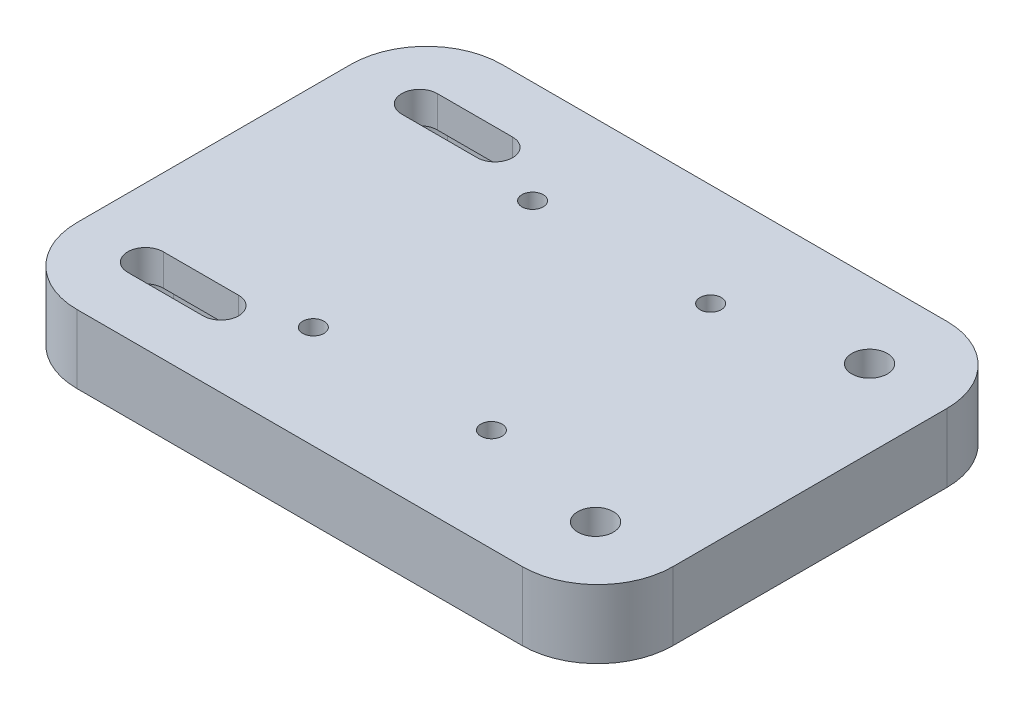
from build123d import *

# Parameters (mm, degrees)
BOSS_EXTRUDE1_DEPTH = 10
CUT_EXTRUDE5_REACH  = 12
SKETCH8_R           = 2.6
SKETCH9_R           = 4.1
CUT_EXTRUDE6_DEPTH  = 5.4
CUT_EXTRUDE7_REACH  = 89
SKETCH11_R          = 1.6
CUT_EXTRUDE8_DEPTH  = 3
CUT_EXTRUDE9_REACH  = 12
SKETCH14_R          = 1.55
CUT_EXTRUDE10_DEPTH = 2.6


with BuildPart() as part:
    # Sketch1 → Boss-Extrude1 (new body)
    with BuildSketch(Plane(origin=(0, 0, 0), x_dir=(1, 0, 0), z_dir=(0, 1, 0))):
        with BuildLine():
            Line((0, 11), (0, 51))
            ThreePointArc((0, 51), (3.221825407, 58.778174593), (11, 62))
            Line((11, 62), (76, 62))
            ThreePointArc((76, 62), (83.778174593, 58.778174593), (87, 51))
            Line((87, 51), (87, 11))
            ThreePointArc((87, 11), (83.778174593, 3.221825407), (76, 0))
            Line((76, 0), (11, 0))
            ThreePointArc((11, 0), (3.221825407, 3.221825407), (0, 11))
        make_face()
    extrude(amount=BOSS_EXTRUDE1_DEPTH)

    # Sketch8 → Cut-Extrude5 (cut, up to next)
    with BuildSketch(Plane(origin=(0, 10, 0), x_dir=(1, 0, 0), z_dir=(0, 1, 0)), mode=Mode.PRIVATE) as cut_extrude5_sk1:
        with Locations((75.7, 51)):
            Circle(SKETCH8_R)
    cut_extrude5_tool1 = extrude(cut_extrude5_sk1.sketch, amount=-CUT_EXTRUDE5_REACH, mode=Mode.PRIVATE) & part.part
    add(cut_extrude5_tool1.solids().sort_by_distance((75.7, 10, -51))[0], mode=Mode.SUBTRACT)
    # Sketch8 → Cut-Extrude5 (cut, up to next)
    with BuildSketch(Plane(origin=(0, 10, 0), x_dir=(1, 0, 0), z_dir=(0, 1, 0)), mode=Mode.PRIVATE) as cut_extrude5_sk2:
        with Locations((75.7, 11)):
            Circle(SKETCH8_R)
    cut_extrude5_tool2 = extrude(cut_extrude5_sk2.sketch, amount=-CUT_EXTRUDE5_REACH, mode=Mode.PRIVATE) & part.part
    add(cut_extrude5_tool2.solids().sort_by_distance((75.7, 10, -11))[0], mode=Mode.SUBTRACT)
    # Sketch8 → Cut-Extrude5 (cut, up to next)
    with BuildSketch(Plane(origin=(0, 10, 0), x_dir=(1, 0, 0), z_dir=(0, 1, 0)), mode=Mode.PRIVATE) as cut_extrude5_sk3:
        with BuildLine():
            Line((10, 53.6), (21, 53.6))
            ThreePointArc((21, 53.6), (23.6, 51), (21, 48.4))
            Line((21, 48.4), (10, 48.4))
            ThreePointArc((10, 48.4), (7.4, 51), (10, 53.6))
        make_face()
    cut_extrude5_tool3 = extrude(cut_extrude5_sk3.sketch, amount=-CUT_EXTRUDE5_REACH, mode=Mode.PRIVATE) & part.part
    add(cut_extrude5_tool3.solids().sort_by_distance((15.5, 10, -51))[0], mode=Mode.SUBTRACT)
    # Sketch8 → Cut-Extrude5 (cut, up to next)
    with BuildSketch(Plane(origin=(0, 10, 0), x_dir=(1, 0, 0), z_dir=(0, 1, 0)), mode=Mode.PRIVATE) as cut_extrude5_sk4:
        with BuildLine():
            Line((10, 13.6), (21, 13.6))
            ThreePointArc((21, 13.6), (23.6, 11), (21, 8.4))
            Line((21, 8.4), (10, 8.4))
            ThreePointArc((10, 8.4), (7.4, 11), (10, 13.6))
        make_face()
    cut_extrude5_tool4 = extrude(cut_extrude5_sk4.sketch, amount=-CUT_EXTRUDE5_REACH, mode=Mode.PRIVATE) & part.part
    add(cut_extrude5_tool4.solids().sort_by_distance((15.5, 10, -11))[0], mode=Mode.SUBTRACT)

    # Sketch9 → Cut-Extrude6 (cut)
    with BuildSketch(Plane.XZ):
        with Locations((75.7, -11)):
            Circle(SKETCH9_R)
        with Locations((75.7, -51)):
            Circle(SKETCH9_R)
        with BuildLine():
            Line((10, -6.9), (21, -6.9))
            ThreePointArc((21, -6.9), (25.1, -11), (21, -15.1))
            Line((21, -15.1), (10, -15.1))
            ThreePointArc((10, -15.1), (8.336419524, -14.747332385), (6.95902976, -13.75))
            Line((6.95902976, -13.75), (3, -13.75))
            Line((3, -13.75), (3, -8.25))
            Line((3, -8.25), (6.95902976, -8.25))
            ThreePointArc((6.95902976, -8.25), (8.336419524, -7.252667615), (10, -6.9))
        make_face()
        with BuildLine():
            Line((10, -46.9), (21, -46.9))
            ThreePointArc((21, -46.9), (25.1, -51), (21, -55.1))
            Line((21, -55.1), (10, -55.1))
            ThreePointArc((10, -55.1), (8.336419524, -54.747332385), (6.95902976, -53.75))
            Line((6.95902976, -53.75), (3, -53.75))
            Line((3, -53.75), (3, -48.25))
            Line((3, -48.25), (6.95902976, -48.25))
            ThreePointArc((6.95902976, -48.25), (8.336419524, -47.252667615), (10, -46.9))
        make_face()
    extrude(amount=-CUT_EXTRUDE6_DEPTH, mode=Mode.SUBTRACT)

    # Sketch11 → Cut-Extrude7 (cut, up to next)
    with BuildSketch(Plane.ZY, mode=Mode.PRIVATE) as cut_extrude7_sk1:
        with Locations((-11, 5)):
            Circle(SKETCH11_R)
    cut_extrude7_tool1 = extrude(cut_extrude7_sk1.sketch, amount=-CUT_EXTRUDE7_REACH, mode=Mode.PRIVATE) & part.part
    add(cut_extrude7_tool1.solids().sort_by_distance((0, 5, -11))[0], mode=Mode.SUBTRACT)
    # Sketch11 → Cut-Extrude7 (cut, up to next)
    with BuildSketch(Plane.ZY, mode=Mode.PRIVATE) as cut_extrude7_sk2:
        with Locations((-51, 5)):
            Circle(SKETCH11_R)
    cut_extrude7_tool2 = extrude(cut_extrude7_sk2.sketch, amount=-CUT_EXTRUDE7_REACH, mode=Mode.PRIVATE) & part.part
    add(cut_extrude7_tool2.solids().sort_by_distance((0, 5, -51))[0], mode=Mode.SUBTRACT)

    # Sketch12 → Cut-Extrude8 (cut)
    with BuildSketch(Plane(origin=(3, 0, 0), x_dir=(0, 0, -1), z_dir=(1, 0, 0))):
        Polygon((48.25, 6.58771324), (48.25, 3.41228676), (51, 1.824573519), (53.75, 3.41228676), (53.75, 6.58771324), (51, 8.175426481), align=None)
        Polygon((13.75, 3.41228676), (13.75, 6.58771324), (11, 8.175426481), (8.25, 6.58771324), (8.25, 3.41228676), (11, 1.824573519), align=None)
    extrude(amount=CUT_EXTRUDE8_DEPTH, mode=Mode.SUBTRACT)

    # Sketch14 → Cut-Extrude9 (cut, up to next)
    with BuildSketch(Plane(origin=(0, 10, 0), x_dir=(1, 0, 0), z_dir=(0, 1, 0)), mode=Mode.PRIVATE) as cut_extrude9_sk1:
        with Locations((30.5, 47)):
            Circle(SKETCH14_R)
    cut_extrude9_tool1 = extrude(cut_extrude9_sk1.sketch, amount=-CUT_EXTRUDE9_REACH, mode=Mode.PRIVATE) & part.part
    add(cut_extrude9_tool1.solids().sort_by_distance((30.5, 10, -47))[0], mode=Mode.SUBTRACT)
    # Sketch14 → Cut-Extrude9 (cut, up to next)
    with BuildSketch(Plane(origin=(0, 10, 0), x_dir=(1, 0, 0), z_dir=(0, 1, 0)), mode=Mode.PRIVATE) as cut_extrude9_sk2:
        with Locations((56.5, 47)):
            Circle(SKETCH14_R)
    cut_extrude9_tool2 = extrude(cut_extrude9_sk2.sketch, amount=-CUT_EXTRUDE9_REACH, mode=Mode.PRIVATE) & part.part
    add(cut_extrude9_tool2.solids().sort_by_distance((56.5, 10, -47))[0], mode=Mode.SUBTRACT)
    # Sketch14 → Cut-Extrude9 (cut, up to next)
    with BuildSketch(Plane(origin=(0, 10, 0), x_dir=(1, 0, 0), z_dir=(0, 1, 0)), mode=Mode.PRIVATE) as cut_extrude9_sk3:
        with Locations((30.5, 15)):
            Circle(SKETCH14_R)
    cut_extrude9_tool3 = extrude(cut_extrude9_sk3.sketch, amount=-CUT_EXTRUDE9_REACH, mode=Mode.PRIVATE) & part.part
    add(cut_extrude9_tool3.solids().sort_by_distance((30.5, 10, -15))[0], mode=Mode.SUBTRACT)
    # Sketch14 → Cut-Extrude9 (cut, up to next)
    with BuildSketch(Plane(origin=(0, 10, 0), x_dir=(1, 0, 0), z_dir=(0, 1, 0)), mode=Mode.PRIVATE) as cut_extrude9_sk4:
        with Locations((56.5, 15)):
            Circle(SKETCH14_R)
    cut_extrude9_tool4 = extrude(cut_extrude9_sk4.sketch, amount=-CUT_EXTRUDE9_REACH, mode=Mode.PRIVATE) & part.part
    add(cut_extrude9_tool4.solids().sort_by_distance((56.5, 10, -15))[0], mode=Mode.SUBTRACT)

    # Sketch15 → Cut-Extrude10 (cut)
    with BuildSketch(Plane.XZ):
        Polygon((33.733161507, -15), (32.116580754, -12.2), (28.883419246, -12.2), (27.266838493, -15), (28.883419246, -17.8), (32.116580754, -17.8), align=None)
        Polygon((59.733161507, -15), (58.116580754, -12.2), (54.883419246, -12.2), (53.266838493, -15), (54.883419246, -17.8), (58.116580754, -17.8), align=None)
        Polygon((59.733161507, -47), (58.116580754, -44.2), (54.883419246, -44.2), (53.266838493, -47), (54.883419246, -49.8), (58.116580754, -49.8), align=None)
        Polygon((33.733161507, -47), (32.116580754, -44.2), (28.883419246, -44.2), (27.266838493, -47), (28.883419246, -49.8), (32.116580754, -49.8), align=None)
    extrude(amount=-CUT_EXTRUDE10_DEPTH, mode=Mode.SUBTRACT)


solid = part.part
